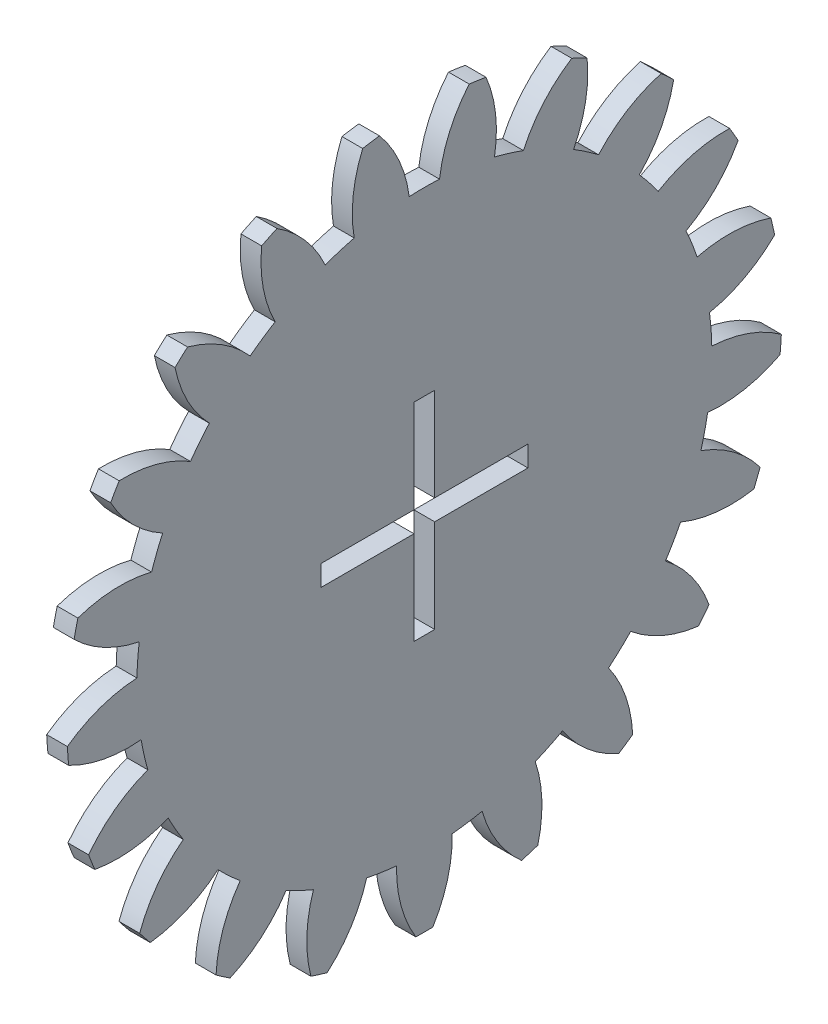
from build123d import *

# Parameters (mm, degrees)
BASPROSKE_W        = 3
BASPROSKE_H        = 51.75
TOOTHCUT_DEPTH     = 74.247013591
TEETHCUTS_COUNT    = 21
TEETHCUTS_ANGLE    = 342.857142857
BORSKE_R           = 0.45
BORE_DEPTH         = 50.0000508
CUT_EXTRUDE1_DEPTH = 74.199531789


with BuildPart() as part:
    # BasProSke → Base-Revolve (revolve)
    with BuildSketch(Plane(origin=(0, 0, 0), x_dir=(1, 0, 0), z_dir=(0, 1, 0)), mode=Mode.PRIVATE) as base_revolve_sk:
        with Locations((1.5, 25.875)):
            Rectangle(BASPROSKE_W, BASPROSKE_H)
    revolve(base_revolve_sk.sketch.rotate(Axis((-10, 0, 0), (1, 0, 0)), 180), axis=Axis((-10, 0, 0), (1, 0, 0)))

    # TooCutSke → ToothCut (cut, through all)
    with BuildSketch(Plane(origin=(0, 0, 0), x_dir=(0, 0, -1), z_dir=(1, 0, 0))):
        with BuildLine():
            ThreePointArc((2.192126265, 41.566235798), (0, 41.624), (-2.192126265, 41.566235798))
            ThreePointArc((-2.192126265, 41.566235798), (-3.643354331, 46.777563157), (-6.511386997, 51.364325018))
            ThreePointArc((-6.511386997, 51.364325018), (0, 51.7754), (6.511386997, 51.364325018))
            ThreePointArc((6.511386997, 51.364325018), (3.643354331, 46.777563157), (2.192126265, 41.566235798))
        make_face()
    toothcut = extrude(amount=TOOTHCUT_DEPTH, mode=Mode.SUBTRACT)

    # TeethCuts: ToothCut ×21 about axis
    teethcuts_axis = Axis((-10, 0, 0), (1, 0, 0))
    for i in range(1, TEETHCUTS_COUNT):
        add(toothcut.rotate(teethcuts_axis, i * TEETHCUTS_ANGLE / (TEETHCUTS_COUNT - 1)), mode=Mode.SUBTRACT)

    # BorSke → Bore (cut, symmetric)
    with BuildSketch(Plane(origin=(0, 0, 0), x_dir=(0, 0, -1), z_dir=(1, 0, 0))):
        with Locations(Location((0, 0, 0), (0, 0, 180))):
            Circle(BORSKE_R)
    extrude(amount=BORE_DEPTH, both=True, mode=Mode.SUBTRACT)

    # Sketch1 → Cut-Extrude1 (cut, through all)
    with BuildSketch(Plane(origin=(3, 0, 0), x_dir=(0, 0, -1), z_dir=(1, 0, 0))):
        Polygon((1.5, 1.95), (15, 1.95), (15, -1.05), (1.5, -1.05), (1.5, -14.55), (-1.5, -14.55), (-1.5, -1.05), (-15, -1.05), (-15, 1.95), (-1.5, 1.95), (-1.5, 15.45), (1.5, 15.45), align=None)
    extrude(amount=-CUT_EXTRUDE1_DEPTH, mode=Mode.SUBTRACT)


solid = part.part
